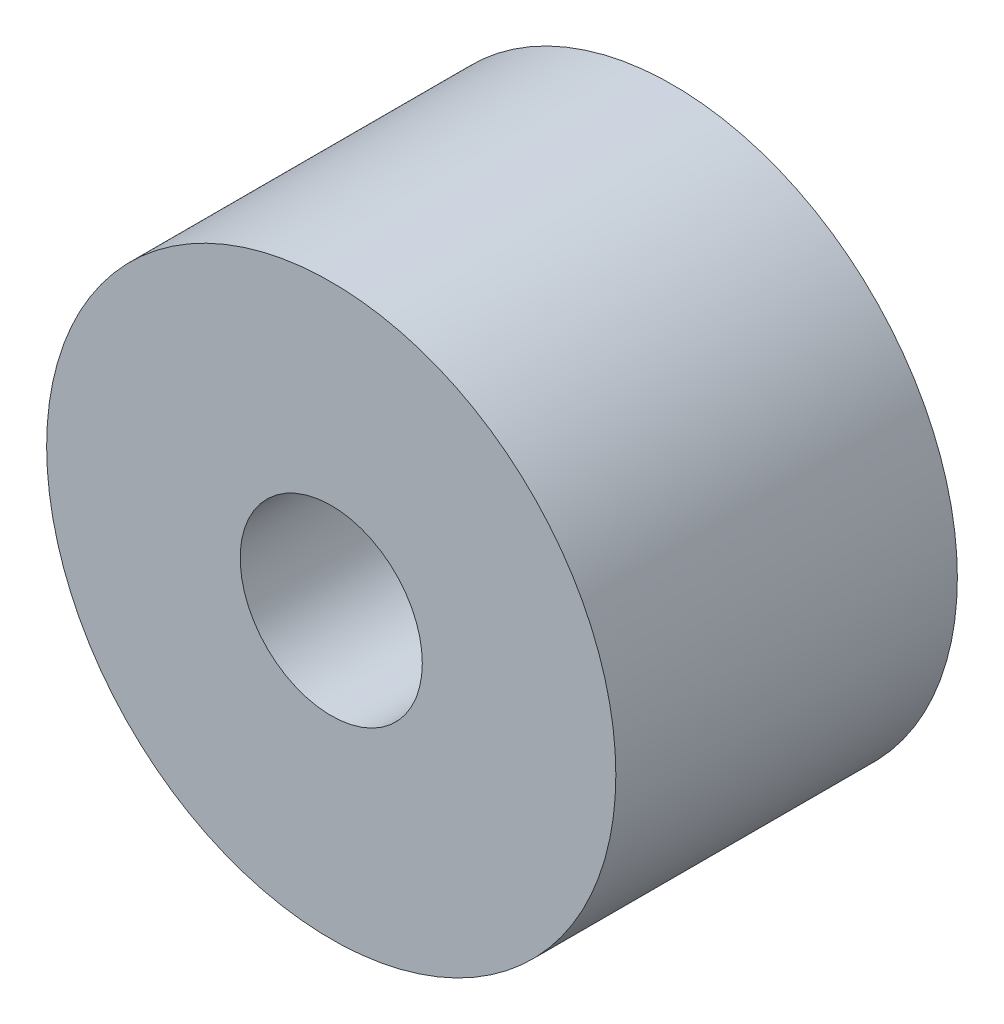
from build123d import *

# Parameters (mm, degrees)
SKETCH1_R           = 12.5
SKETCH1_R_2         = 4
BOSS_EXTRUDE2_DEPTH = 15


with BuildPart() as part:
    # Sketch1 → Boss-Extrude2 (new body)
    with BuildSketch(Plane.XY):
        Circle(SKETCH1_R)
        Circle(SKETCH1_R_2, mode=Mode.SUBTRACT)
    extrude(amount=BOSS_EXTRUDE2_DEPTH)


solid = part.part
